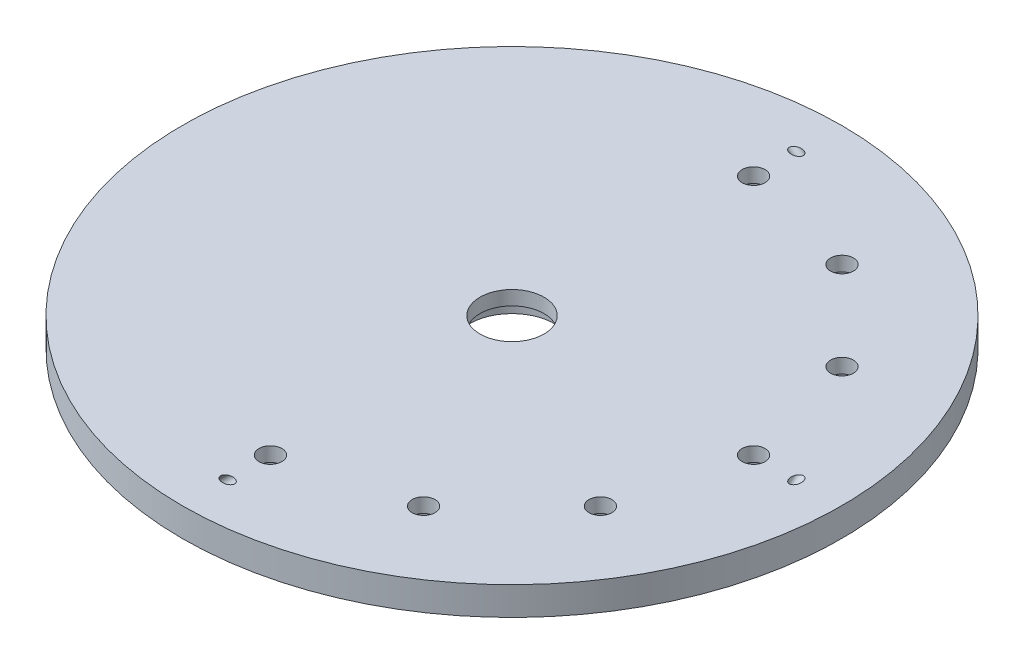
from build123d import *

# Parameters (mm, degrees)
SKETCH1_R                       = 73.63206
SKETCH1_R_2                     = 9.525
SKETCH1_R_3                     = 7.14375
BOSS_EXTRUDE1_DEPTH             = 6.35
CIRPATTERN1_COUNT               = 2
CIRPATTERN1_ANGLE               = 90
CIRPATTERN1_THE_OTHER_WAY_COUNT = 2
CIRPATTERN1_THE_OTHER_WAY_ANGLE = 90
SKETCH1_4_R                     = 9.525
SKETCH1_4_R_2                   = 7.14375
CUT_EXTRUDE2_DEPTH              = 3.175
CIRPATTERN2_COUNT               = 12


with BuildPart() as part:
    # Sketch1 → Boss-Extrude1 (new body)
    with BuildSketch(Plane(origin=(0, 0, 0), x_dir=(1, 0, 0), z_dir=(0, 1, 0))):
        Circle(SKETCH1_R)
        Circle(SKETCH1_R_2, mode=Mode.SUBTRACT)
        Circle(SKETCH1_R_2)
        Circle(SKETCH1_R_3, mode=Mode.SUBTRACT)
    extrude(amount=BOSS_EXTRUDE1_DEPTH)

    # Sketch2 → Nozzle (revolve, cut)
    with BuildSketch(Plane(origin=(63.53048, 0, 0), x_dir=(0, 0, -1), z_dir=(1, 0, 0))):
        Polygon((-17.960512242, -11.610512242), (17.960512242, 24.310512242), (17.170249703, 25.100774781), (-3.330262539, 4.600262539), (-22.882688583, -6.688335901), align=None)
    nozzle = revolve(axis=Axis((63.53048, 24.310512242, -17.960512242), (0, -0.707106781, 0.707106781)), mode=Mode.SUBTRACT)

    # CirPattern1: Nozzle ×2 about axis
    cirpattern1_axis = Axis((0, 6.35, 0), (0, -1, 0))
    for i in range(1, CIRPATTERN1_COUNT):
        add(nozzle.rotate(cirpattern1_axis, i * CIRPATTERN1_ANGLE / (CIRPATTERN1_COUNT - 1)), mode=Mode.SUBTRACT)

    # CirPattern1 the other way: Nozzle ×2 about axis
    cirpattern1_the_other_way_axis = Axis((0, 6.35, 0), (0, 1, 0))
    for i in range(1, CIRPATTERN1_THE_OTHER_WAY_COUNT):
        add(nozzle.rotate(cirpattern1_the_other_way_axis, i * CIRPATTERN1_THE_OTHER_WAY_ANGLE / (CIRPATTERN1_THE_OTHER_WAY_COUNT - 1)), mode=Mode.SUBTRACT)

    # Sketch1_4 → Cut-Extrude2 (cut)
    with BuildSketch(Plane(origin=(0, 0, 0), x_dir=(1, 0, 0), z_dir=(0, 1, 0))):
        Circle(SKETCH1_4_R)
        Circle(SKETCH1_4_R_2, mode=Mode.SUBTRACT)
    extrude(amount=CUT_EXTRUDE2_DEPTH, mode=Mode.SUBTRACT)

    # Sketch5 → CBORE for _10 Binding Head Machine Screw (revolve, cut)
    with BuildSketch(Plane(origin=(53.975, 0, 0), x_dir=(0, 0, -1), z_dir=(1, 0, 0))):
        Polygon((0, 0), (0, 15.503816902), (2.5527, 13.97), (2.5527, 3.1242), (5.55625, 3.1242), (5.55625, 0), align=None)
    cbore_for_10_binding_head_machine_screw = revolve(axis=Axis((53.975, -6.35, 0), (0, 1, 0)), mode=Mode.SUBTRACT)

    # CirPattern2: CBORE for _10 Binding Head Machine Screw ×12 about axis, 5 skipped
    cirpattern2_axis = Axis((0, 0, 0), (0, -1, 0))
    add([cbore_for_10_binding_head_machine_screw.rotate(cirpattern2_axis, i * 360 / CIRPATTERN2_COUNT) for i in range(1, CIRPATTERN2_COUNT) if i not in (4, 5, 6, 7, 8)], mode=Mode.SUBTRACT)


solid = part.part
